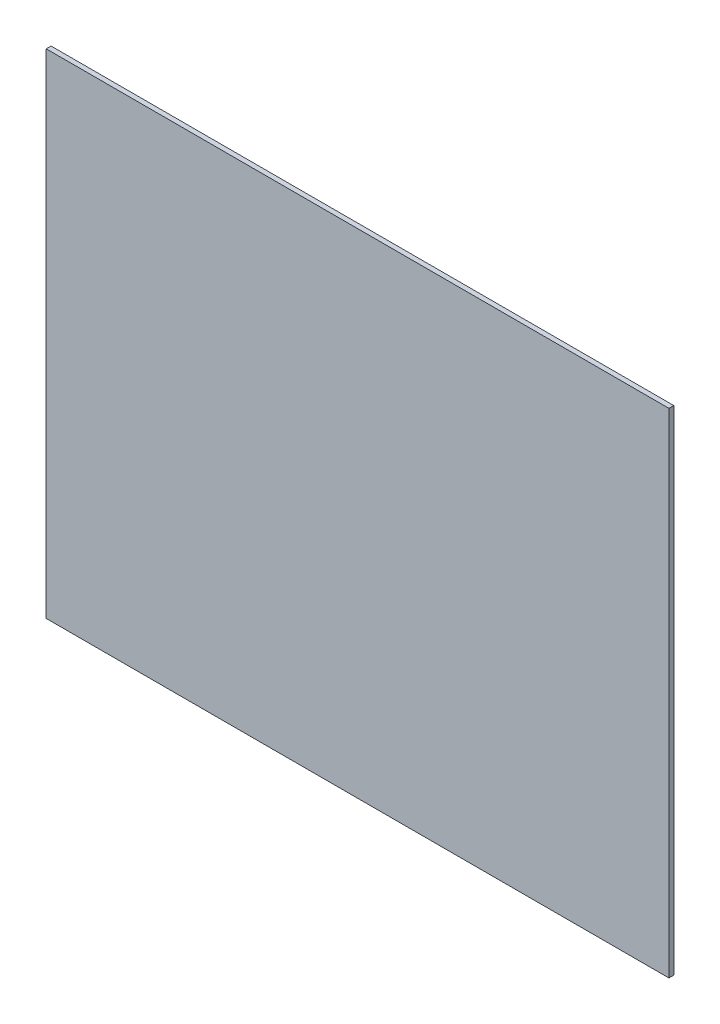
from build123d import *

# Parameters (mm, degrees)
CROQUIS1_W              = 385
CROQUIS1_H              = 305
SALIENTE_EXTRUIR1_DEPTH = 3


with BuildPart() as part:
    # Croquis1 → Saliente-Extruir1 (new body)
    with BuildSketch(Plane.XY):
        with Locations((192.5, 152.5)):
            Rectangle(CROQUIS1_W, CROQUIS1_H)
    extrude(amount=SALIENTE_EXTRUIR1_DEPTH)


solid = part.part
